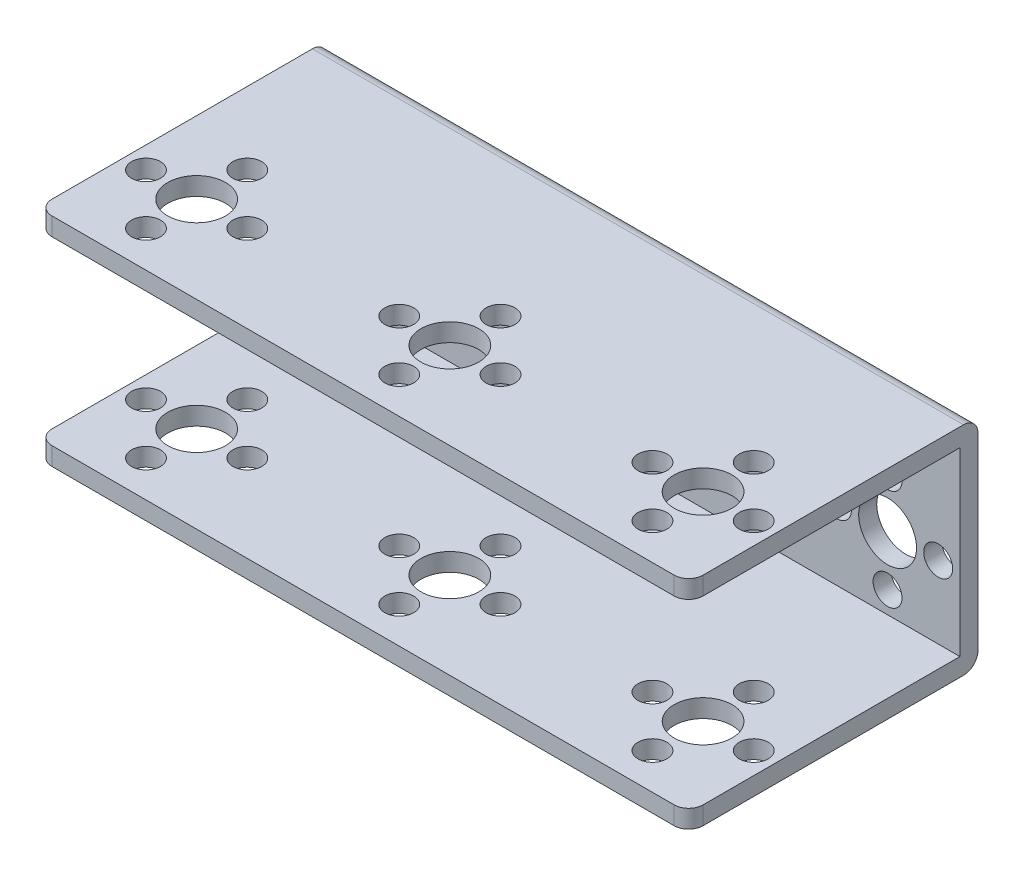
from build123d import *

# Parameters (mm, degrees)
SKETCH_1_W          = 90
SKETCH_1_H          = 40
EXTRUDE_1_DEPTH     = 30
SKETCH_2_W          = 90
SKETCH_2_H          = 25
CUT_EXTRUDE_1_DEPTH = 37.5
SKETCH_3_R          = 4
SKETCH_3_R_2        = 2
CUT_EXTRUDE_2_DEPTH = 2.5
CUT_EXTRUDE_3_REACH = 42
SKETCH_4_R          = 4
SKETCH_4_R_2        = 2
FILLET_1_R          = 2
FILLET_2_R          = 2
FILLET_3_R          = 2
FILLET_4_R          = 2
FILLET_5_R          = 2
FILLET_6_R          = 2


with BuildPart() as part:
    # 草图1 → 凸台-拉伸1 (new body)
    with BuildSketch(Plane(origin=(0, 0, 0), x_dir=(1, 0, 0), z_dir=(0, 1, 0))):
        Rectangle(SKETCH_1_W, SKETCH_1_H)
    extrude(amount=EXTRUDE_1_DEPTH)

    # 草图2 → 切除-拉伸1 (cut)
    with BuildSketch(Plane.XY.offset(20)):
        with Locations((0, 15)):
            Rectangle(SKETCH_2_W, SKETCH_2_H)
    extrude(amount=-CUT_EXTRUDE_1_DEPTH, mode=Mode.SUBTRACT)

    # 草图3 → 切除-拉伸2 (cut)
    with BuildSketch(Plane(origin=(0, 30, 0), x_dir=(1, 0, 0), z_dir=(0, 1, 0))):
        with Locations((35, -8)):
            Circle(SKETCH_3_R)
        with Locations((42, -8)):
            Circle(SKETCH_3_R_2)
        with Locations((35, -15)):
            Circle(SKETCH_3_R_2)
        with Locations((28, -8)):
            Circle(SKETCH_3_R_2)
        with Locations((35, -1)):
            Circle(SKETCH_3_R_2)
        with Locations((0, -8)):
            Circle(SKETCH_3_R)
        with Locations((-7, -8)):
            Circle(SKETCH_3_R_2)
        with Locations((0, -1)):
            Circle(SKETCH_3_R_2)
        with Locations((0, -15)):
            Circle(SKETCH_3_R_2)
        with Locations((7, -8)):
            Circle(SKETCH_3_R_2)
        with Locations((-35, -8)):
            Circle(SKETCH_3_R)
        with Locations((-42, -8)):
            Circle(SKETCH_3_R_2)
        with Locations((-35, -1)):
            Circle(SKETCH_3_R_2)
        with Locations((-35, -15)):
            Circle(SKETCH_3_R_2)
        with Locations((-28, -8)):
            Circle(SKETCH_3_R_2)
    cut_extrude_2 = extrude(amount=-CUT_EXTRUDE_2_DEPTH, mode=Mode.SUBTRACT)

    # 镜向1: 切除-拉伸2 across plane
    add(cut_extrude_2.mirror(Plane(origin=(0, 15, 0), x_dir=(0, 0, 1), z_dir=(0, -1, 0))), mode=Mode.SUBTRACT)

    # 草图4 → 切除-拉伸3 (cut, up to next)
    with BuildSketch(Plane(origin=(0, 0, -20), x_dir=(-1, 0, 0), z_dir=(0, 0, -1)), mode=Mode.PRIVATE) as cut_extrude_3_sk1:
        with Locations((35, 12.5)):
            Circle(SKETCH_4_R)
    cut_extrude_3_tool1 = extrude(cut_extrude_3_sk1.sketch, amount=-CUT_EXTRUDE_3_REACH, mode=Mode.PRIVATE) & part.part
    add(cut_extrude_3_tool1.solids().sort_by_distance((-35, 12.5, -20))[0], mode=Mode.SUBTRACT)
    # 草图4 → 切除-拉伸3 (cut, up to next)
    with BuildSketch(Plane(origin=(0, 0, -20), x_dir=(-1, 0, 0), z_dir=(0, 0, -1)), mode=Mode.PRIVATE) as cut_extrude_3_sk2:
        with Locations((42, 12.5)):
            Circle(SKETCH_4_R_2)
    cut_extrude_3_tool2 = extrude(cut_extrude_3_sk2.sketch, amount=-CUT_EXTRUDE_3_REACH, mode=Mode.PRIVATE) & part.part
    add(cut_extrude_3_tool2.solids().sort_by_distance((-42, 12.5, -20))[0], mode=Mode.SUBTRACT)
    # 草图4 → 切除-拉伸3 (cut, up to next)
    with BuildSketch(Plane(origin=(0, 0, -20), x_dir=(-1, 0, 0), z_dir=(0, 0, -1)), mode=Mode.PRIVATE) as cut_extrude_3_sk3:
        with Locations((35, 5.5)):
            Circle(SKETCH_4_R_2)
    cut_extrude_3_tool3 = extrude(cut_extrude_3_sk3.sketch, amount=-CUT_EXTRUDE_3_REACH, mode=Mode.PRIVATE) & part.part
    add(cut_extrude_3_tool3.solids().sort_by_distance((-35, 5.5, -20))[0], mode=Mode.SUBTRACT)
    # 草图4 → 切除-拉伸3 (cut, up to next)
    with BuildSketch(Plane(origin=(0, 0, -20), x_dir=(-1, 0, 0), z_dir=(0, 0, -1)), mode=Mode.PRIVATE) as cut_extrude_3_sk4:
        with Locations((28, 12.5)):
            Circle(SKETCH_4_R_2)
    cut_extrude_3_tool4 = extrude(cut_extrude_3_sk4.sketch, amount=-CUT_EXTRUDE_3_REACH, mode=Mode.PRIVATE) & part.part
    add(cut_extrude_3_tool4.solids().sort_by_distance((-28, 12.5, -20))[0], mode=Mode.SUBTRACT)
    # 草图4 → 切除-拉伸3 (cut, up to next)
    with BuildSketch(Plane(origin=(0, 0, -20), x_dir=(-1, 0, 0), z_dir=(0, 0, -1)), mode=Mode.PRIVATE) as cut_extrude_3_sk5:
        with Locations((35, 19.5)):
            Circle(SKETCH_4_R_2)
    cut_extrude_3_tool5 = extrude(cut_extrude_3_sk5.sketch, amount=-CUT_EXTRUDE_3_REACH, mode=Mode.PRIVATE) & part.part
    add(cut_extrude_3_tool5.solids().sort_by_distance((-35, 19.5, -20))[0], mode=Mode.SUBTRACT)
    # 草图4 → 切除-拉伸3 (cut, up to next)
    with BuildSketch(Plane(origin=(0, 0, -20), x_dir=(-1, 0, 0), z_dir=(0, 0, -1)), mode=Mode.PRIVATE) as cut_extrude_3_sk6:
        with Locations((7, 12.5)):
            Circle(SKETCH_4_R_2)
    cut_extrude_3_tool6 = extrude(cut_extrude_3_sk6.sketch, amount=-CUT_EXTRUDE_3_REACH, mode=Mode.PRIVATE) & part.part
    add(cut_extrude_3_tool6.solids().sort_by_distance((-7, 12.5, -20))[0], mode=Mode.SUBTRACT)
    # 草图4 → 切除-拉伸3 (cut, up to next)
    with BuildSketch(Plane(origin=(0, 0, -20), x_dir=(-1, 0, 0), z_dir=(0, 0, -1)), mode=Mode.PRIVATE) as cut_extrude_3_sk7:
        with Locations((0, 12.5)):
            Circle(SKETCH_4_R)
    cut_extrude_3_tool7 = extrude(cut_extrude_3_sk7.sketch, amount=-CUT_EXTRUDE_3_REACH, mode=Mode.PRIVATE) & part.part
    add(cut_extrude_3_tool7.solids().sort_by_distance((0, 12.5, -20))[0], mode=Mode.SUBTRACT)
    # 草图4 → 切除-拉伸3 (cut, up to next)
    with BuildSketch(Plane(origin=(0, 0, -20), x_dir=(-1, 0, 0), z_dir=(0, 0, -1)), mode=Mode.PRIVATE) as cut_extrude_3_sk8:
        with Locations((-7, 12.5)):
            Circle(SKETCH_4_R_2)
    cut_extrude_3_tool8 = extrude(cut_extrude_3_sk8.sketch, amount=-CUT_EXTRUDE_3_REACH, mode=Mode.PRIVATE) & part.part
    add(cut_extrude_3_tool8.solids().sort_by_distance((7, 12.5, -20))[0], mode=Mode.SUBTRACT)
    # 草图4 → 切除-拉伸3 (cut, up to next)
    with BuildSketch(Plane(origin=(0, 0, -20), x_dir=(-1, 0, 0), z_dir=(0, 0, -1)), mode=Mode.PRIVATE) as cut_extrude_3_sk9:
        with Locations((0, 5.5)):
            Circle(SKETCH_4_R_2)
    cut_extrude_3_tool9 = extrude(cut_extrude_3_sk9.sketch, amount=-CUT_EXTRUDE_3_REACH, mode=Mode.PRIVATE) & part.part
    add(cut_extrude_3_tool9.solids().sort_by_distance((0, 5.5, -20))[0], mode=Mode.SUBTRACT)
    # 草图4 → 切除-拉伸3 (cut, up to next)
    with BuildSketch(Plane(origin=(0, 0, -20), x_dir=(-1, 0, 0), z_dir=(0, 0, -1)), mode=Mode.PRIVATE) as cut_extrude_3_sk10:
        with Locations((0, 19.5)):
            Circle(SKETCH_4_R_2)
    cut_extrude_3_tool10 = extrude(cut_extrude_3_sk10.sketch, amount=-CUT_EXTRUDE_3_REACH, mode=Mode.PRIVATE) & part.part
    add(cut_extrude_3_tool10.solids().sort_by_distance((0, 19.5, -20))[0], mode=Mode.SUBTRACT)
    # 草图4 → 切除-拉伸3 (cut, up to next)
    with BuildSketch(Plane(origin=(0, 0, -20), x_dir=(-1, 0, 0), z_dir=(0, 0, -1)), mode=Mode.PRIVATE) as cut_extrude_3_sk11:
        with Locations((-28, 12.5)):
            Circle(SKETCH_4_R_2)
    cut_extrude_3_tool11 = extrude(cut_extrude_3_sk11.sketch, amount=-CUT_EXTRUDE_3_REACH, mode=Mode.PRIVATE) & part.part
    add(cut_extrude_3_tool11.solids().sort_by_distance((28, 12.5, -20))[0], mode=Mode.SUBTRACT)
    # 草图4 → 切除-拉伸3 (cut, up to next)
    with BuildSketch(Plane(origin=(0, 0, -20), x_dir=(-1, 0, 0), z_dir=(0, 0, -1)), mode=Mode.PRIVATE) as cut_extrude_3_sk12:
        with Locations((-35, 12.5)):
            Circle(SKETCH_4_R)
    cut_extrude_3_tool12 = extrude(cut_extrude_3_sk12.sketch, amount=-CUT_EXTRUDE_3_REACH, mode=Mode.PRIVATE) & part.part
    add(cut_extrude_3_tool12.solids().sort_by_distance((35, 12.5, -20))[0], mode=Mode.SUBTRACT)
    # 草图4 → 切除-拉伸3 (cut, up to next)
    with BuildSketch(Plane(origin=(0, 0, -20), x_dir=(-1, 0, 0), z_dir=(0, 0, -1)), mode=Mode.PRIVATE) as cut_extrude_3_sk13:
        with Locations((-42, 12.5)):
            Circle(SKETCH_4_R_2)
    cut_extrude_3_tool13 = extrude(cut_extrude_3_sk13.sketch, amount=-CUT_EXTRUDE_3_REACH, mode=Mode.PRIVATE) & part.part
    add(cut_extrude_3_tool13.solids().sort_by_distance((42, 12.5, -20))[0], mode=Mode.SUBTRACT)
    # 草图4 → 切除-拉伸3 (cut, up to next)
    with BuildSketch(Plane(origin=(0, 0, -20), x_dir=(-1, 0, 0), z_dir=(0, 0, -1)), mode=Mode.PRIVATE) as cut_extrude_3_sk14:
        with Locations((-35, 5.5)):
            Circle(SKETCH_4_R_2)
    cut_extrude_3_tool14 = extrude(cut_extrude_3_sk14.sketch, amount=-CUT_EXTRUDE_3_REACH, mode=Mode.PRIVATE) & part.part
    add(cut_extrude_3_tool14.solids().sort_by_distance((35, 5.5, -20))[0], mode=Mode.SUBTRACT)
    # 草图4 → 切除-拉伸3 (cut, up to next)
    with BuildSketch(Plane(origin=(0, 0, -20), x_dir=(-1, 0, 0), z_dir=(0, 0, -1)), mode=Mode.PRIVATE) as cut_extrude_3_sk15:
        with Locations((-35, 19.5)):
            Circle(SKETCH_4_R_2)
    cut_extrude_3_tool15 = extrude(cut_extrude_3_sk15.sketch, amount=-CUT_EXTRUDE_3_REACH, mode=Mode.PRIVATE) & part.part
    add(cut_extrude_3_tool15.solids().sort_by_distance((35, 19.5, -20))[0], mode=Mode.SUBTRACT)

    # 圆角1
    fillet_1_edges = [part.edges().sort_by_distance(p)[0] for p in [
        (-45, 28.75, 20),
    ]]
    fillet(fillet_1_edges, radius=FILLET_1_R)

    # 圆角2
    fillet_2_edges = [part.edges().sort_by_distance(p)[0] for p in [
        (45, 28.75, 20),
    ]]
    fillet(fillet_2_edges, radius=FILLET_2_R)

    # 圆角3
    fillet_3_edges = [part.edges().sort_by_distance(p)[0] for p in [
        (45, 1.25, 20),
    ]]
    fillet(fillet_3_edges, radius=FILLET_3_R)

    # 圆角4
    fillet_4_edges = [part.edges().sort_by_distance(p)[0] for p in [
        (-45, 1.25, 20),
    ]]
    fillet(fillet_4_edges, radius=FILLET_4_R)

    # 圆角5
    fillet_5_edges = [part.edges().sort_by_distance(p)[0] for p in [
        (0, 0, -20),
    ]]
    fillet(fillet_5_edges, radius=FILLET_5_R)

    # 圆角6
    fillet_6_edges = [part.edges().sort_by_distance(p)[0] for p in [
        (0, 30, -20),
    ]]
    fillet(fillet_6_edges, radius=FILLET_6_R)


solid = part.part
